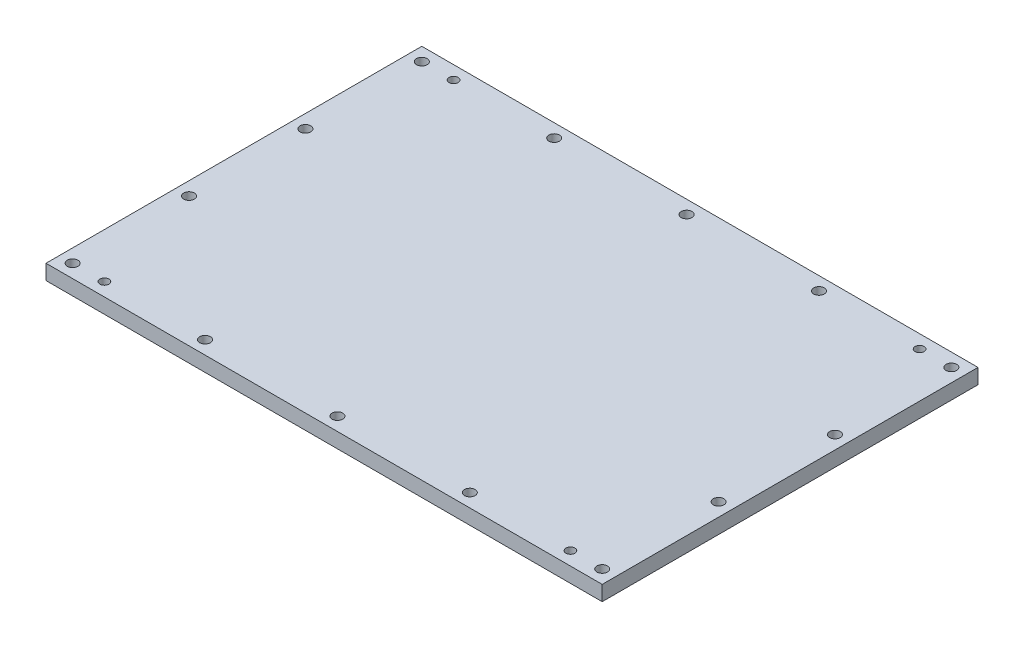
from build123d import *

# Parameters (mm, degrees)
SKETCH1_W             = 234.95
SKETCH1_H             = 158.75
BOSS_EXTRUDE1_DEPTH   = 6.35
F_8_CLEARANCE_HOLE1_D = 4.4958
F_6_CLEARANCE_HOLE1_D = 3.7973


with BuildPart() as part:
    # Sketch1 → Boss-Extrude1 (new body)
    with BuildSketch(Plane(origin=(0, 0, 0), x_dir=(1, 0, 0), z_dir=(0, 1, 0))):
        Rectangle(SKETCH1_W, SKETCH1_H)
    extrude(amount=BOSS_EXTRUDE1_DEPTH)

    # #8 Clearance Hole1 (through all)
    with Locations(Plane(origin=(0, 6.35, 0), x_dir=(1, 0, 0), z_dir=(0, 1, 0))):
        with Locations((0, 73.7489), (-55.92445, 73.7489), (-111.8489, 73.7489), (-111.8489, 24.582966667), (-111.8489, -24.582966667), (-111.8489, -73.7489), (111.8489, -73.7489), (111.8489, -24.582966667), (111.8489, 24.582966667), (55.92445, 73.7489), (111.8489, 73.7489), (55.92445, -73.7489), (0, -73.7489), (-55.92445, -73.7489)):
            Hole(F_8_CLEARANCE_HOLE1_D / 2)

    # #6 Clearance Hole1 (through all)
    with Locations(Plane(origin=(0, 6.35, 0), x_dir=(1, 0, 0), z_dir=(0, 1, 0))):
        with Locations((-98.425, 73.7489), (-98.425, -73.7489), (98.425, 73.7489), (98.425, -73.7489)):
            Hole(F_6_CLEARANCE_HOLE1_D / 2)


solid = part.part
